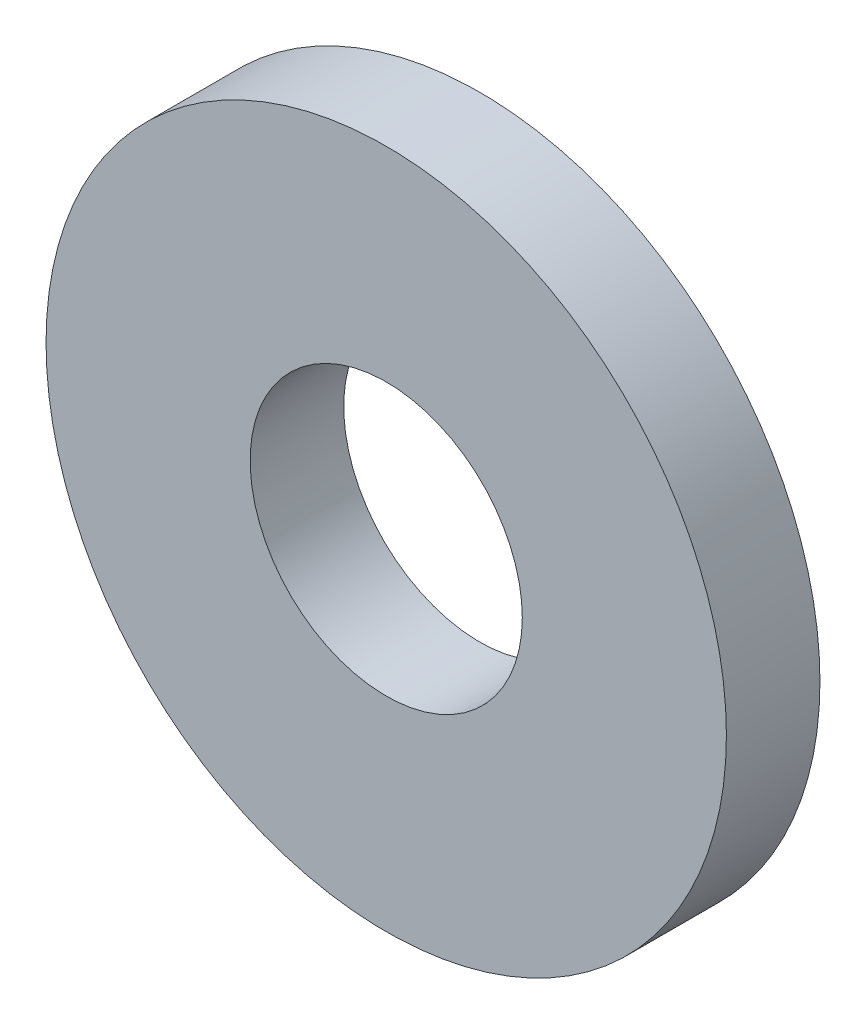
from build123d import *

# Parameters (mm, degrees)
SKETCH1_R           = 4
SKETCH1_R_2         = 1.6
BOSS_EXTRUDE1_DEPTH = 1.1


with BuildPart() as part:
    # Sketch1 → Boss-Extrude1 (new body)
    with BuildSketch(Plane.XY):
        Circle(SKETCH1_R)
        Circle(SKETCH1_R_2, mode=Mode.SUBTRACT)
    extrude(amount=BOSS_EXTRUDE1_DEPTH)


solid = part.part
